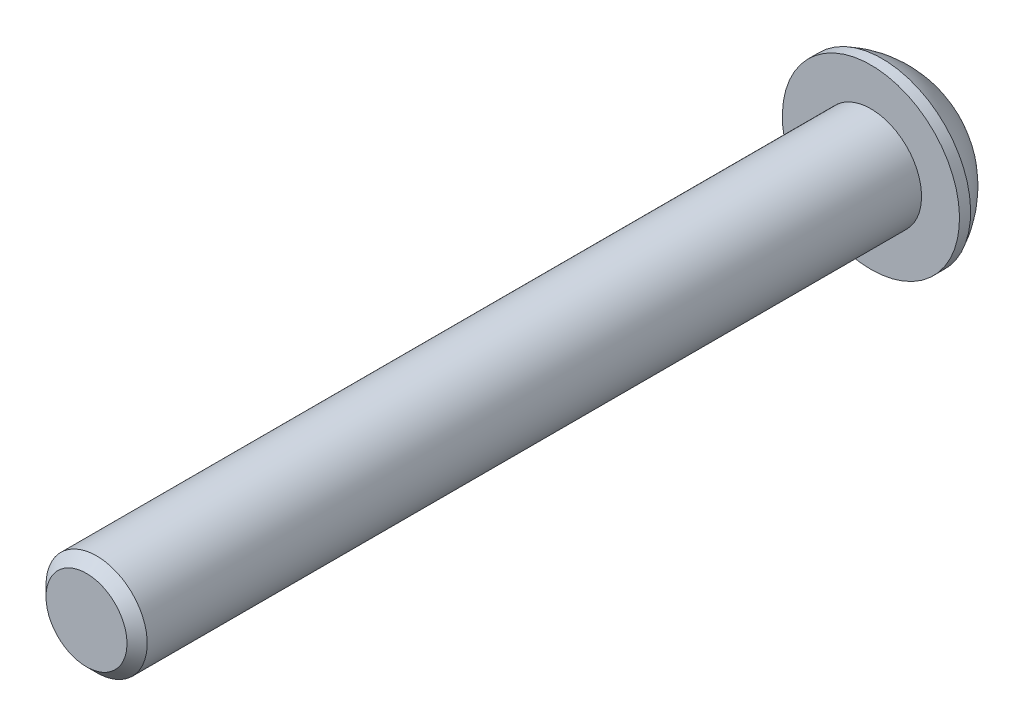
from build123d import *

# Parameters (mm, degrees)
HEX_2_DEPTH = 2.816


with BuildPart() as part:
    # sk3 → br (revolve)
    with BuildSketch(Plane(origin=(0, 0, 0), x_dir=(0, 0, -1), z_dir=(1, 0, 0)), mode=Mode.PRIVATE) as br_sk:
        Polygon((-62, 3.2), (-61.2, 4), (0, 4), (0, 0), (-62, 0), align=None)
    revolve(br_sk.sketch.rotate(Axis((0, 0, 0), (0, 0, -1)), 270), axis=Axis((0, 0, 0), (0, 0, -1)))  # turned: the seam where the file's is

    # sk1 → hd (revolve)
    with BuildSketch(Plane.ZY, mode=Mode.PRIVATE) as hd_sk:
        with BuildLine():
            Line((0, 0), (0, 7))
            Line((0, 7), (-0.88, 7))
            ThreePointArc((-0.88, 7), (-2.92552474, 5.53715631), (-4.4, 3.5))
            Line((-4.4, 3.5), (-4.4, 0))
            Line((-4.4, 0), (0, 0))
        make_face()
    revolve(hd_sk.sketch.rotate(Axis((0, 0, 0), (0, 0, -1)), 270), axis=Axis((0, 0, 0), (0, 0, -1)))  # turned: the seam where the file's is

    # sk2 → hex 2 (cut)
    with BuildSketch(Plane(origin=(0, 0, -4.4), x_dir=(-1, 0, 0), z_dir=(0, 0, -1))):
        Polygon((1.443375673, 2.5), (-1.443375673, 2.5), (-2.886751346, 0), (-1.443375673, -2.5), (1.443375673, -2.5), (2.886751346, 0), align=None)
    extrude(amount=-HEX_2_DEPTH, mode=Mode.SUBTRACT)


solid = part.part
